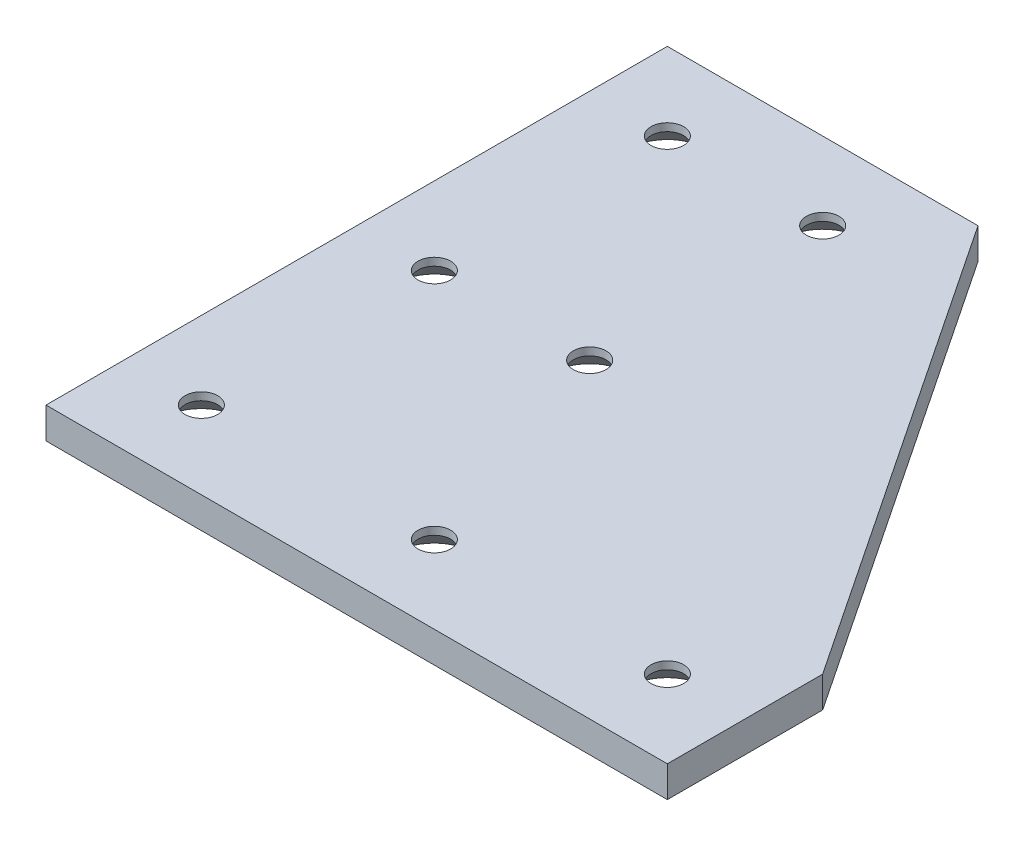
from build123d import *

# Parameters (mm, degrees)
BOSS_EXTRUDE1_DEPTH = 4
SKETCH2_R           = 2.1
CUT_EXTRUDE1_DEPTH  = 4
CHAMFER1_SIZE       = 3


with BuildPart() as part:
    # Sketch1 → Boss-Extrude1 (new body)
    with BuildSketch(Plane(origin=(0, 0, 0), x_dir=(1, 0, 0), z_dir=(0, 1, 0))):
        Polygon((0, 0), (80, 0), (80, 20), (40, 80), (0, 80), align=None)
    extrude(amount=BOSS_EXTRUDE1_DEPTH)

    # Sketch2 → Cut-Extrude1 (cut)
    with BuildSketch(Plane(origin=(0, 4, 0), x_dir=(1, 0, 0), z_dir=(0, 1, 0))):
        with Locations((10, 10)):
            Circle(SKETCH2_R)
        with Locations((40, 10)):
            Circle(SKETCH2_R)
        with Locations((70, 10)):
            Circle(SKETCH2_R)
        with Locations((30, 40)):
            Circle(SKETCH2_R)
        with Locations((30, 70)):
            Circle(SKETCH2_R)
        with Locations((10, 40)):
            Circle(SKETCH2_R)
        with Locations((10, 70)):
            Circle(SKETCH2_R)
    extrude(amount=-CUT_EXTRUDE1_DEPTH, mode=Mode.SUBTRACT)

    # Chamfer1
    chamfer1_edges = [part.edges().sort_by_distance(p)[0] for p in [
        (7.9, 0, -70),
        (7.9, 0, -40),
        (27.9, 0, -70),
        (27.9, 0, -40),
        (67.9, 0, -10),
        (37.9, 0, -10),
        (7.9, 0, -10),
    ]]
    chamfer(chamfer1_edges, length=CHAMFER1_SIZE)


solid = part.part
